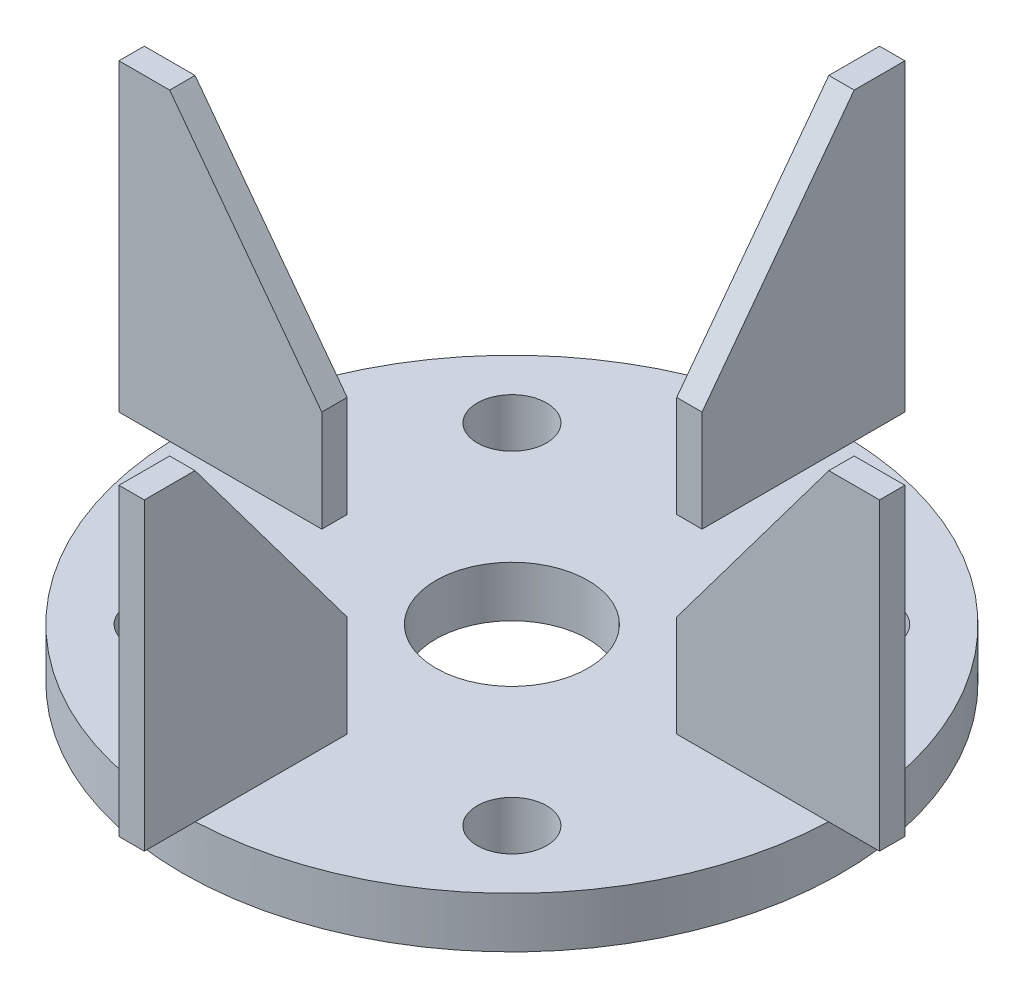
from build123d import *

# Parameters (mm, degrees)
SKETCH3_R           = 82.55
SKETCH3_R_2         = 19.05
BOSS_EXTRUDE2_DEPTH = 12.7
BOSS_EXTRUDE3_DEPTH = 3.175
CIRPATTERN1_COUNT   = 4
SKETCH8_R           = 8.686637198
CUT_EXTRUDE6_DEPTH  = 89.9


with BuildPart() as part:
    # Sketch3 → Boss-Extrude2 (new body)
    with BuildSketch(Plane(origin=(0, 0, 0), x_dir=(1, 0, 0), z_dir=(0, 1, 0))):
        Circle(SKETCH3_R)
        Circle(SKETCH3_R_2, mode=Mode.SUBTRACT)
    extrude(amount=BOSS_EXTRUDE2_DEPTH)

    # Sketch5 → Boss-Extrude3 (add, symmetric)
    with BuildSketch(Plane(origin=(0, 0, 0), x_dir=(0, 0, -1), z_dir=(1, 0, 0))):
        Polygon((-82.55, 88.9), (-44.45, 38.1), (-44.45, 12.7), (-95.25, 12.7), (-95.25, 88.9), align=None)
    boss_extrude3 = extrude(amount=BOSS_EXTRUDE3_DEPTH, both=True)

    # CirPattern1: Boss-Extrude3 ×4 about axis
    cirpattern1_axis = Axis((0, 0, 0), (0, 1, 0))
    for i in range(1, CIRPATTERN1_COUNT):
        add(boss_extrude3.rotate(cirpattern1_axis, i * 360 / CIRPATTERN1_COUNT))

    # Sketch8 → Cut-Extrude6 (cut, through all)
    with BuildSketch(Plane(origin=(0, 0, 0), x_dir=(1, 0, 0), z_dir=(0, 1, 0))):
        with Locations((43.68002845, -43.68002845)):
            Circle(SKETCH8_R)
        with Locations((-43.68002845, -43.68002845)):
            Circle(SKETCH8_R)
        with Locations((-43.68002845, 43.68002845)):
            Circle(SKETCH8_R)
        with Locations((43.68002845, 43.68002845)):
            Circle(SKETCH8_R)
    extrude(amount=CUT_EXTRUDE6_DEPTH, mode=Mode.SUBTRACT)


solid = part.part
